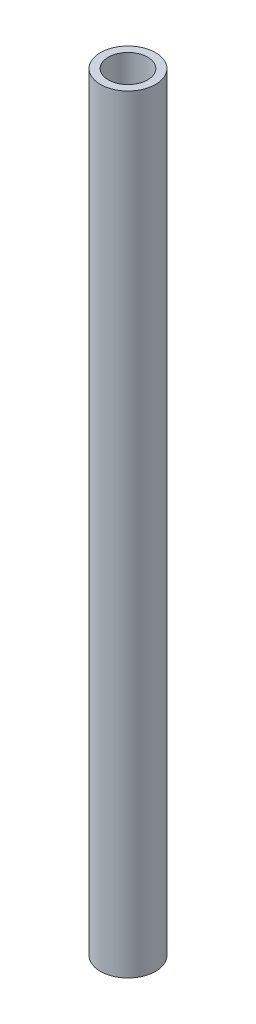
from build123d import *

# Parameters (mm, degrees)
SKETCH1_R           = 7
SKETCH1_R_2         = 5
BOSS_EXTRUDE1_DEPTH = 195


with BuildPart() as part:
    # Sketch1 → Boss-Extrude1 (new body)
    with BuildSketch(Plane(origin=(0, 0, 0), x_dir=(1, 0, 0), z_dir=(0, 1, 0))):
        Circle(SKETCH1_R)
        Circle(SKETCH1_R_2, mode=Mode.SUBTRACT)
    extrude(amount=BOSS_EXTRUDE1_DEPTH)


solid = part.part
